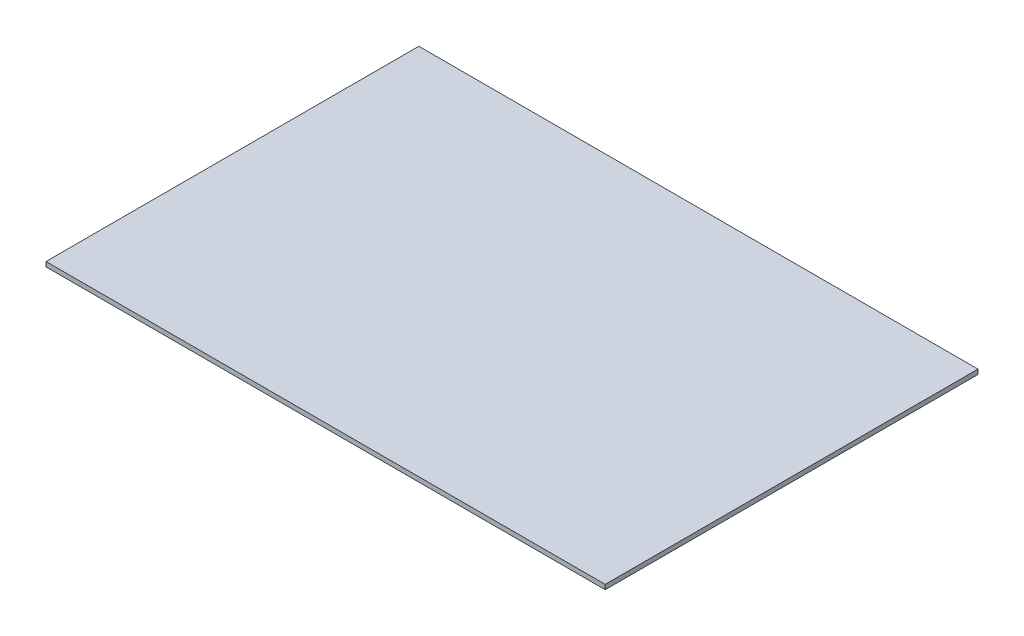
from build123d import *

# Parameters (mm, degrees)
SKETCH1_W           = 12000
SKETCH1_H           = 8000
BOSS_EXTRUDE1_DEPTH = 100


with BuildPart() as part:
    # Sketch1 → Boss-Extrude1 (new body)
    with BuildSketch(Plane(origin=(0, 0, 0), x_dir=(1, 0, 0), z_dir=(0, 1, 0))):
        with Locations((6000, 4000)):
            Rectangle(SKETCH1_W, SKETCH1_H)
    extrude(amount=BOSS_EXTRUDE1_DEPTH)


solid = part.part
